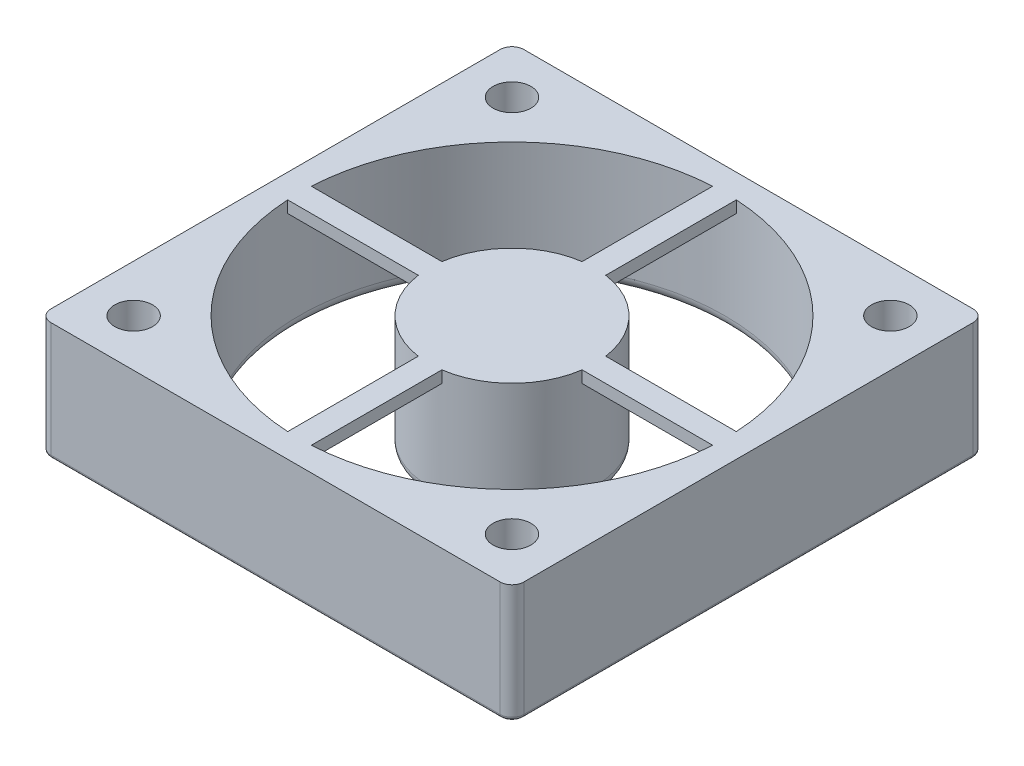
from build123d import *

# Parameters (mm, degrees)
SKETCH1_W           = 40
SKETCH1_H           = 40
BOSS_EXTRUDE1_DEPTH = 10
FILLET1_R           = 1
SKETCH2_R           = 18
SKETCH2_R_2         = 7
CUT_EXTRUDE2_DEPTH  = 10
SKETCH3_R           = 1.6
CUT_EXTRUDE3_DEPTH  = 11
BOSS_EXTRUDE2_DEPTH = 1
FILLET2_R           = 1
FILLET3_R           = 1
FILLET4_R           = 0.3


with BuildPart() as part:
    # Sketch1 → Boss-Extrude1 (new body)
    with BuildSketch(Plane(origin=(0, 0, 0), x_dir=(1, 0, 0), z_dir=(0, 1, 0))):
        with Locations((-20, 20)):
            Rectangle(SKETCH1_W, SKETCH1_H)
    extrude(amount=BOSS_EXTRUDE1_DEPTH)

    # Fillet1
    fillet1_edges = [part.edges().sort_by_distance(p)[0] for p in [
        (0, 5, 0),
        (-40, 5, 0),
        (-40, 5, -40),
        (0, 5, -40),
    ]]
    fillet(fillet1_edges, radius=FILLET1_R)

    # Sketch2 → Cut-Extrude2 (cut)
    with BuildSketch(Plane(origin=(0, 10, 0), x_dir=(1, 0, 0), z_dir=(0, 1, 0))):
        with Locations((-20, 20)):
            Circle(SKETCH2_R)
        with Locations((-20, 20)):
            Circle(SKETCH2_R_2, mode=Mode.SUBTRACT)
    extrude(amount=-CUT_EXTRUDE2_DEPTH, mode=Mode.SUBTRACT)

    # Sketch3 → Cut-Extrude3 (cut, through all)
    with BuildSketch(Plane(origin=(0, 10, 0), x_dir=(1, 0, 0), z_dir=(0, 1, 0))):
        with Locations((-36, 36)):
            Circle(SKETCH3_R)
        with Locations((-4, 36)):
            Circle(SKETCH3_R)
        with Locations((-4, 4)):
            Circle(SKETCH3_R)
        with Locations((-36, 4)):
            Circle(SKETCH3_R)
    extrude(amount=-CUT_EXTRUDE3_DEPTH, mode=Mode.SUBTRACT)

    # Sketch7 → Boss-Extrude2 (add)
    with BuildSketch(Plane(origin=(0, 10, 0), x_dir=(1, 0, 0), z_dir=(0, 1, 0))):
        with BuildLine():
            Line((-21, 21), (-37.972200756, 21))
            ThreePointArc((-37.972200756, 21), (-38, 20), (-37.972200756, 19))
            Line((-37.972200756, 19), (-21, 19))
            Line((-21, 19), (-21, 21))
        make_face()
        with BuildLine():
            Line((-21, 37.972200756), (-21, 21))
            Line((-21, 21), (-19, 21))
            Line((-19, 21), (-19, 37.972200756))
            ThreePointArc((-19, 37.972200756), (-20, 38), (-21, 37.972200756))
        make_face()
        with BuildLine():
            Line((-2.027799244, 21), (-19, 21))
            Line((-19, 21), (-19, 19))
            Line((-19, 19), (-2.027799244, 19))
            ThreePointArc((-2.027799244, 19), (-2.006951153, 19.499806838), (-2, 20))
            ThreePointArc((-2, 20), (-2.006951153, 20.500193162), (-2.027799244, 21))
        make_face()
        with BuildLine():
            Line((-19, 19), (-21, 19))
            Line((-21, 19), (-21, 2.027799244))
            ThreePointArc((-21, 2.027799244), (-20, 2), (-19, 2.027799244))
            Line((-19, 2.027799244), (-19, 19))
        make_face()
    extrude(amount=-BOSS_EXTRUDE2_DEPTH)

    # Fillet2
    fillet2_edges = [part.edges().sort_by_distance(p)[0] for p in [
        (-27, 0, -20),
    ]]
    fillet(fillet2_edges, radius=FILLET2_R)

    # Fillet3
    fillet3_edges = [part.edges().sort_by_distance(p)[0] for p in [
        (-38, 0, -20),
    ]]
    fillet(fillet3_edges, radius=FILLET3_R)

    # Fillet4
    fillet4_edges = [part.edges().sort_by_distance(p)[0] for p in [
        (0, 0, -20),
        (-20, 0, -40),
        (-40, 0, -20),
        (-20, 0, 0),
        (-0.292893219, 0, -39.707106781),
        (-0.292893219, 0, -0.292893219),
        (-39.707106781, 0, -0.292893219),
        (-39.707106781, 0, -39.707106781),
    ]]
    fillet(fillet4_edges, radius=FILLET4_R)


solid = part.part
